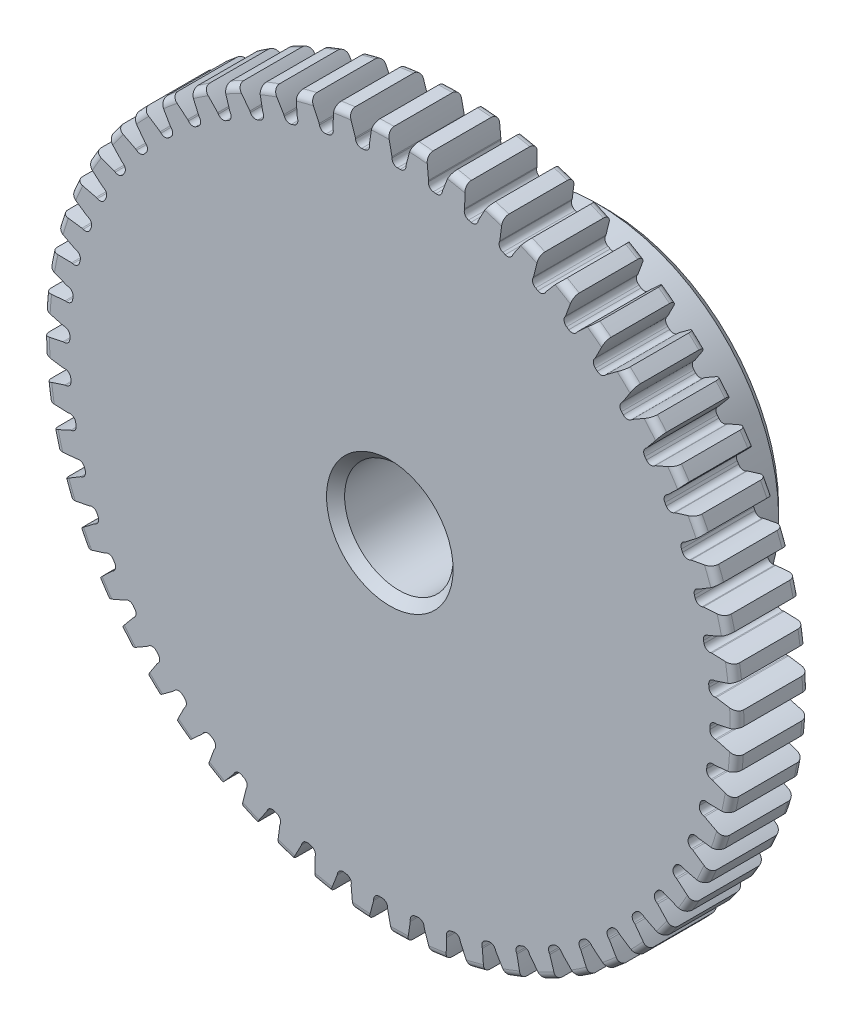
from build123d import *

# Parameters (mm, degrees)
SKETCH1_R                = 15.24
BOSS_EXTRUDE1_DEPTH      = 3.175
SKETCH2_W                = 6.35
SKETCH2_H                = 7.9375
FILLET2_R                = 0.3048
CUT_EXTRUDE1_DEPTH       = 10.525
FILLET1_R                = 0.249435747
CIRPATTERN1_COUNT        = 56
FILLET1_OF_CIRPATTERN1_R = 0.249435747
SKETCH5_R                = 2.38125
CUT_EXTRUDE2_DEPTH       = 10.525
CHAMFER1_SIZE            = 0.396875


with BuildPart() as part:
    # Sketch1 → Boss-Extrude1 (new body)
    with BuildSketch(Plane.XY):
        Circle(SKETCH1_R)
    extrude(amount=-BOSS_EXTRUDE1_DEPTH)

    # Sketch2 → Revolve1 (revolve)
    with BuildSketch(Plane(origin=(0, 0, 0), x_dir=(0, 0, -1), z_dir=(1, 0, 0))):
        with Locations((6.35, 3.96875)):
            Rectangle(SKETCH2_W, SKETCH2_H)
    revolve(axis=Axis((0, 0, -3.175), (0, 0, -1)))

    # Fillet2
    fillet2_edges = [part.edges().sort_by_distance(p)[0] for p in [
        (-15.24, 0, 0),
        (-15.24, 0, -3.175),
        (0, -7.9375, -3.175),
    ]]
    fillet(fillet2_edges, radius=FILLET2_R)

    # Sketch4 → Cut-Extrude1 (cut, through all)
    with BuildSketch(Plane.XY):
        with BuildLine():
            Line((0.09320492, 14.348516647), (0.09320492, 14.048725645))
            ThreePointArc((0.09320492, 14.048725645), (0.394023752, 14.043508276), (0.694661879, 14.031850352))
            Line((0.694661879, 14.031850352), (0.711471334, 14.331169724))
            add(Edge.make_bspline(
                [(2.447892675, 17.314004555), (1.068575643, 16.031856903), (0.711471334, 14.331169724)],
                knots=[0, 0, 0, 1, 1, 1], degree=2))
            ThreePointArc((2.447892675, 17.314004555), (0.490423386, 17.479313979), (-1.473235422, 17.424021053))
            add(Edge.make_bspline(
                [(-1.473235422, 17.424021053), (-0.167979082, 16.066551363), (0.09320492, 14.348516647)],
                knots=[0, 0, 0, 1, 1, 1], degree=2))
        make_face()
    cut_extrude1 = extrude(amount=-CUT_EXTRUDE1_DEPTH, mode=Mode.SUBTRACT)

    # Fillet1
    fillet1_edges = [part.edges().sort_by_distance(p)[0] for p in [
        (0.694661879, 14.031850352, -1.5875),
        (0.09320492, 14.048725645, -1.5875),
    ]]
    fillet(fillet1_edges, radius=FILLET1_R)

    # CirPattern1: Cut-Extrude1 ×56 about axis
    cirpattern1_axis = Axis((0, 0, -3.175), (0, 0, 1))
    for i in range(1, CIRPATTERN1_COUNT):
        add(cut_extrude1.rotate(cirpattern1_axis, i * 360 / CIRPATTERN1_COUNT), mode=Mode.SUBTRACT)

    # Fillet1 of CirPattern1
    fillet1_of_cirpattern1_edges = [part.edges().sort_by_distance(p)[0] for p in [
        (-0.880774782, 14.021398475, -1.5875),
        (-1.48033934, 13.970825847, -1.5875),
        (-2.44513519, 13.834619377, -1.5875),
        (-3.035267474, 13.717234808, -1.5875),
        (-3.978746603, 13.473861914, -1.5875),
        (-4.552025358, 13.291141582, -1.5875),
        (-5.46232297, 12.943662819, -1.5875),
        (-6.011538882, 12.697904539, -1.5875),
        (-6.877207456, 12.250689655, -1.5875),
        (-7.395453816, 11.944983979, -1.5875),
        (-8.205607068, 11.40365696, -1.5875),
        (-8.686366628, 11.041848315, -1.5875),
        (-9.430816411, 10.413216662, -1.5875),
        (-9.86804334, 9.999855002, -1.5875),
        (-10.537427764, 9.291824122, -1.5875),
        (-10.925623681, 8.83210771, -1.5875),
        (-11.51152485, 8.053581504, -1.5875),
        (-11.845807965, 7.553291539, -1.5875),
        (-12.340857832, 6.714060424, -1.5875),
        (-12.617024341, 6.179488344, -1.5875),
        (-13.014997366, 5.29010614, -1.5875),
        (-13.229574315, 4.727974498, -1.5875),
        (-13.525465757, 3.799625701, -1.5875),
        (-13.675754716, 3.217003629, -1.5875),
        (-13.865843568, 2.261362765, -1.5875),
        (-13.949954567, 1.665577074, -1.5875),
        (-14.031850352, 0.694661879, -1.5875),
        (-14.048725645, 0.09320492, -1.5875),
        (-14.021398475, -0.880774782, -1.5875),
        (-13.970825847, -1.48033934, -1.5875),
        (-13.834619377, -2.44513519, -1.5875),
        (-13.717234808, -3.035267474, -1.5875),
        (-13.473861914, -3.978746603, -1.5875),
        (-13.291141582, -4.552025358, -1.5875),
        (-12.943662819, -5.46232297, -1.5875),
        (-12.697904539, -6.011538882, -1.5875),
        (-12.250689655, -6.877207456, -1.5875),
        (-11.944983979, -7.395453816, -1.5875),
        (-11.40365696, -8.205607068, -1.5875),
        (-11.041848315, -8.686366628, -1.5875),
        (-10.413216662, -9.430816411, -1.5875),
        (-9.999855002, -9.86804334, -1.5875),
        (-9.291824122, -10.537427764, -1.5875),
        (-8.83210771, -10.925623681, -1.5875),
        (-8.053581504, -11.51152485, -1.5875),
        (-7.553291539, -11.845807965, -1.5875),
        (-6.714060424, -12.340857832, -1.5875),
        (-6.179488344, -12.617024341, -1.5875),
        (-5.29010614, -13.014997366, -1.5875),
        (-4.727974498, -13.229574315, -1.5875),
        (-3.799625701, -13.525465757, -1.5875),
        (-3.217003629, -13.675754716, -1.5875),
        (-2.261362765, -13.865843568, -1.5875),
        (-1.665577074, -13.949954567, -1.5875),
        (-0.694661879, -14.031850352, -1.5875),
        (-0.09320492, -14.048725645, -1.5875),
        (0.880774782, -14.021398475, -1.5875),
        (1.48033934, -13.970825847, -1.5875),
        (2.44513519, -13.834619377, -1.5875),
        (3.035267474, -13.717234808, -1.5875),
        (3.978746603, -13.473861914, -1.5875),
        (4.552025358, -13.291141582, -1.5875),
        (5.46232297, -12.943662819, -1.5875),
        (6.011538882, -12.697904539, -1.5875),
        (6.877207456, -12.250689655, -1.5875),
        (7.395453816, -11.944983979, -1.5875),
        (8.205607068, -11.40365696, -1.5875),
        (8.686366628, -11.041848315, -1.5875),
        (9.430816411, -10.413216662, -1.5875),
        (9.86804334, -9.999855002, -1.5875),
        (10.537427764, -9.291824122, -1.5875),
        (10.925623681, -8.83210771, -1.5875),
        (11.51152485, -8.053581504, -1.5875),
        (11.845807965, -7.553291539, -1.5875),
        (12.340857832, -6.714060424, -1.5875),
        (12.617024341, -6.179488344, -1.5875),
        (13.014997366, -5.29010614, -1.5875),
        (13.229574315, -4.727974498, -1.5875),
        (13.525465757, -3.799625701, -1.5875),
        (13.675754716, -3.217003629, -1.5875),
        (13.865843568, -2.261362765, -1.5875),
        (13.949954567, -1.665577074, -1.5875),
        (14.031850352, -0.694661879, -1.5875),
        (14.048725645, -0.09320492, -1.5875),
        (14.021398475, 0.880774782, -1.5875),
        (13.970825847, 1.48033934, -1.5875),
        (13.834619377, 2.44513519, -1.5875),
        (13.717234808, 3.035267474, -1.5875),
        (13.473861914, 3.978746603, -1.5875),
        (13.291141582, 4.552025358, -1.5875),
        (12.943662819, 5.46232297, -1.5875),
        (12.697904539, 6.011538882, -1.5875),
        (12.250689655, 6.877207456, -1.5875),
        (11.944983979, 7.395453816, -1.5875),
        (11.40365696, 8.205607068, -1.5875),
        (11.041848315, 8.686366628, -1.5875),
        (10.413216662, 9.430816411, -1.5875),
        (9.999855002, 9.86804334, -1.5875),
        (9.291824122, 10.537427764, -1.5875),
        (8.83210771, 10.925623681, -1.5875),
        (8.053581504, 11.51152485, -1.5875),
        (7.553291539, 11.845807965, -1.5875),
        (6.714060424, 12.340857832, -1.5875),
        (6.179488344, 12.617024341, -1.5875),
        (5.29010614, 13.014997366, -1.5875),
        (4.727974498, 13.229574315, -1.5875),
        (3.799625701, 13.525465757, -1.5875),
        (3.217003629, 13.675754716, -1.5875),
        (2.261362765, 13.865843568, -1.5875),
        (1.665577074, 13.949954567, -1.5875),
    ]]
    fillet(fillet1_of_cirpattern1_edges, radius=FILLET1_OF_CIRPATTERN1_R)

    # Sketch5 → Cut-Extrude2 (cut, through all)
    with BuildSketch(Plane.XY):
        Circle(SKETCH5_R)
    extrude(amount=-CUT_EXTRUDE2_DEPTH, mode=Mode.SUBTRACT)

    # Chamfer1
    chamfer1_edges = [part.edges().sort_by_distance(p)[0] for p in [
        (-2.38125, 0, -9.525),
        (-2.38125, 0, 0),
        (0, -7.9375, -9.525),
    ]]
    chamfer(chamfer1_edges, length=CHAMFER1_SIZE)


solid = part.part
